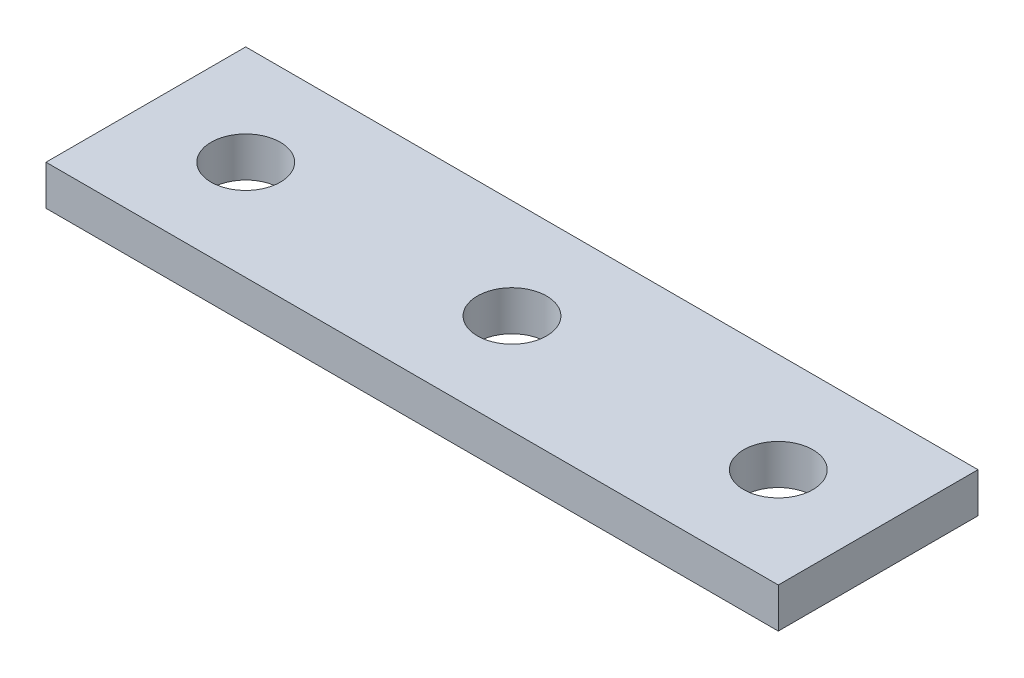
from build123d import *

# Parameters (mm, degrees)
SKETCH_1_W      = 55
SKETCH_1_H      = 15
SKETCH_1_R      = 2.6
EXTRUDE_1_DEPTH = 3


with BuildPart() as part:
    # Эскиз1 → Бобышка-Вытянуть1 (new body)
    with BuildSketch(Plane(origin=(0, 0, 0), x_dir=(1, 0, 0), z_dir=(0, 1, 0))):
        Rectangle(SKETCH_1_W, SKETCH_1_H)
        Circle(SKETCH_1_R, mode=Mode.SUBTRACT)
        with Locations((20, 0)):
            Circle(SKETCH_1_R, mode=Mode.SUBTRACT)
        with Locations((-20, 0)):
            Circle(SKETCH_1_R, mode=Mode.SUBTRACT)
    extrude(amount=EXTRUDE_1_DEPTH)


solid = part.part
